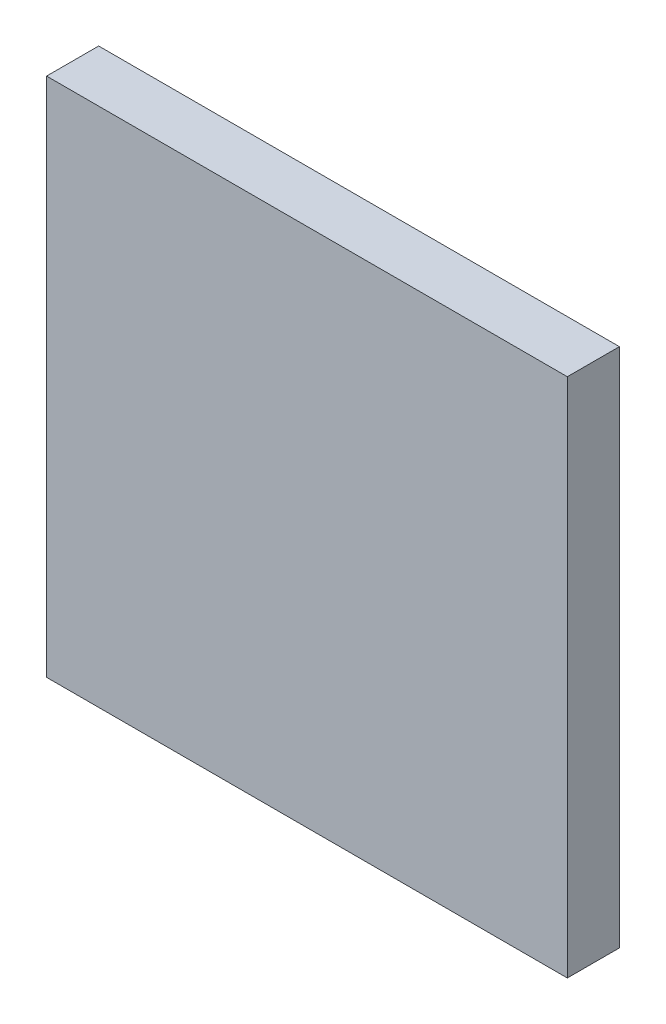
from build123d import *

# Parameters (mm, degrees)
SKETCH1_W           = 5000
SKETCH1_H           = 5000
BOSS_EXTRUDE1_DEPTH = 500


with BuildPart() as part:
    # Sketch1 → Boss-Extrude1 (new body)
    with BuildSketch(Plane.XY):
        Rectangle(SKETCH1_W, SKETCH1_H)
    extrude(amount=BOSS_EXTRUDE1_DEPTH)


solid = part.part
